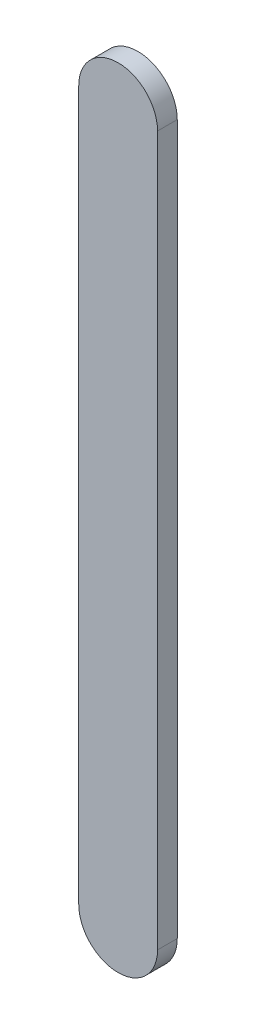
from build123d import *

# Parameters (mm, degrees)
EXTRUDE_1_DEPTH = 5


with BuildPart() as part:
    # 草图1 → 凸台-拉伸1 (new body)
    with BuildSketch(Plane.XY):
        with BuildLine():
            Line((10, 0), (10, -180))
            ThreePointArc((10, -180), (0, -190), (-10, -180))
            Line((-10, -180), (-10, 0))
            ThreePointArc((-10, 0), (0, 10), (10, 0))
        make_face()
    extrude(amount=EXTRUDE_1_DEPTH)


solid = part.part
